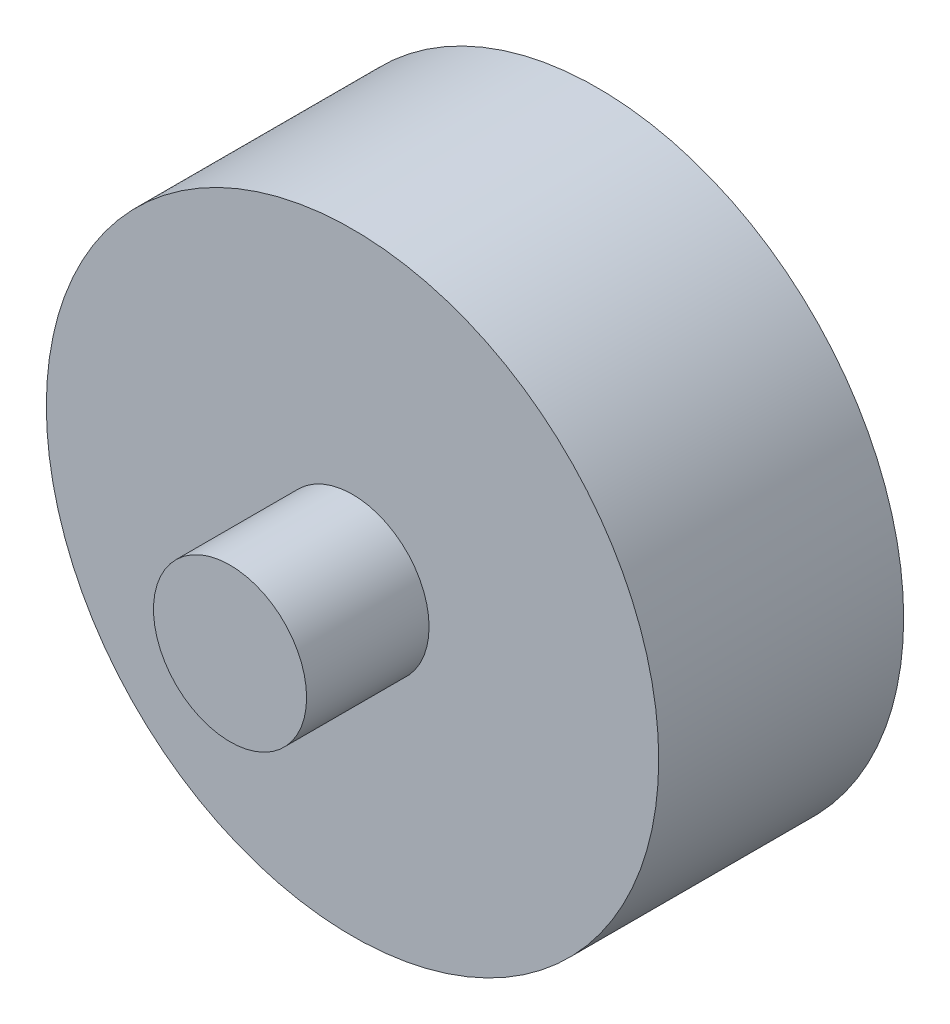
from build123d import *

# Parameters (mm, degrees)
SKETCH1_R           = 2.5
BOSS_EXTRUDE1_DEPTH = 12
SKETCH1_3_R         = 10
SKETCH1_3_R_2       = 2.5
BOSS_EXTRUDE2_DEPTH = 8


with BuildPart() as part:
    # Sketch1 → Boss-Extrude1 (new body)
    with BuildSketch(Plane.XY):
        with Locations((10, 10)):
            Circle(SKETCH1_R)
    extrude(amount=BOSS_EXTRUDE1_DEPTH)

    # Sketch1_3 → Boss-Extrude2 (add)
    with BuildSketch(Plane.XY):
        with Locations((10, 10)):
            Circle(SKETCH1_3_R)
        with Locations((10, 10)):
            Circle(SKETCH1_3_R_2, mode=Mode.SUBTRACT)
    extrude(amount=BOSS_EXTRUDE2_DEPTH)


solid = part.part
